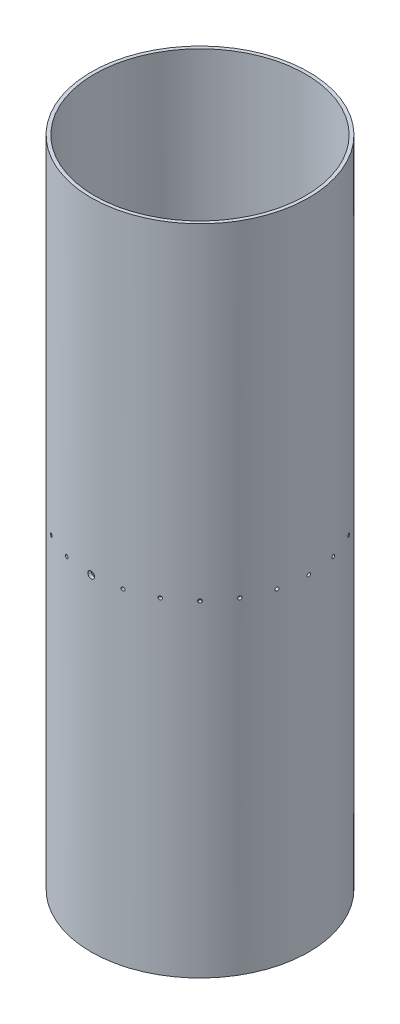
from build123d import *

# Parameters (mm, degrees)
SKETCH1_R               = 101.6
SKETCH1_R_2             = 98.425
BOSS_EXTRUDE1_DEPTH     = 609.6
SKETCH2_R               = 3.175
CUT_EXTRUDE1_DEPTH      = 102.6
CUT_EXTRUDE1_DEPTH_BACK = 102.6
SKETCH3_R               = 1.5875
CUT_EXTRUDE2_DEPTH      = 609.6
CIRPATTERN1_COUNT       = 24
SKETCH5_R               = 2.125
CUT_EXTRUDE3_DEPTH      = 102.6000001
CUT_EXTRUDE3_DEPTH_BACK = 102.6000001


with BuildPart() as part:
    # Sketch1 → Boss-Extrude1 (new body)
    with BuildSketch(Plane(origin=(0, 0, 0), x_dir=(1, 0, 0), z_dir=(0, 1, 0))):
        Circle(SKETCH1_R)
        Circle(SKETCH1_R_2, mode=Mode.SUBTRACT)
    extrude(amount=BOSS_EXTRUDE1_DEPTH)

    # Sketch2 → Cut-Extrude1 (cut, two sides)
    with BuildSketch(Plane.XY) as cut_extrude1_sk:
        with Locations((0, 304.8)):
            Circle(SKETCH2_R)
    extrude(amount=CUT_EXTRUDE1_DEPTH, mode=Mode.SUBTRACT)
    extrude(cut_extrude1_sk.sketch, amount=-CUT_EXTRUDE1_DEPTH_BACK, mode=Mode.SUBTRACT)

    # Sketch3 → Cut-Extrude2 (cut)
    with BuildSketch(Plane(origin=(0, 0, 0), x_dir=(0, 0, -1), z_dir=(1, 0, 0))):
        with Locations((0, 304.8)):
            Circle(SKETCH3_R)
    cut_extrude2 = extrude(amount=-CUT_EXTRUDE2_DEPTH, mode=Mode.SUBTRACT)

    # CirPattern1: Cut-Extrude2 ×24 about axis
    cirpattern1_axis = Axis((0, 0, 0), (0, 1, 0))
    for i in range(1, CIRPATTERN1_COUNT):
        add(cut_extrude2.rotate(cirpattern1_axis, i * 360 / CIRPATTERN1_COUNT), mode=Mode.SUBTRACT)

    # Sketch5 → Cut-Extrude3 (cut, two sides)
    with BuildSketch(Plane.XY) as cut_extrude3_sk:
        with Locations((-84.7725, 447.89984)):
            Circle(SKETCH5_R)
    extrude(amount=CUT_EXTRUDE3_DEPTH, mode=Mode.SUBTRACT)
    extrude(cut_extrude3_sk.sketch, amount=-CUT_EXTRUDE3_DEPTH_BACK, mode=Mode.SUBTRACT)


solid = part.part
